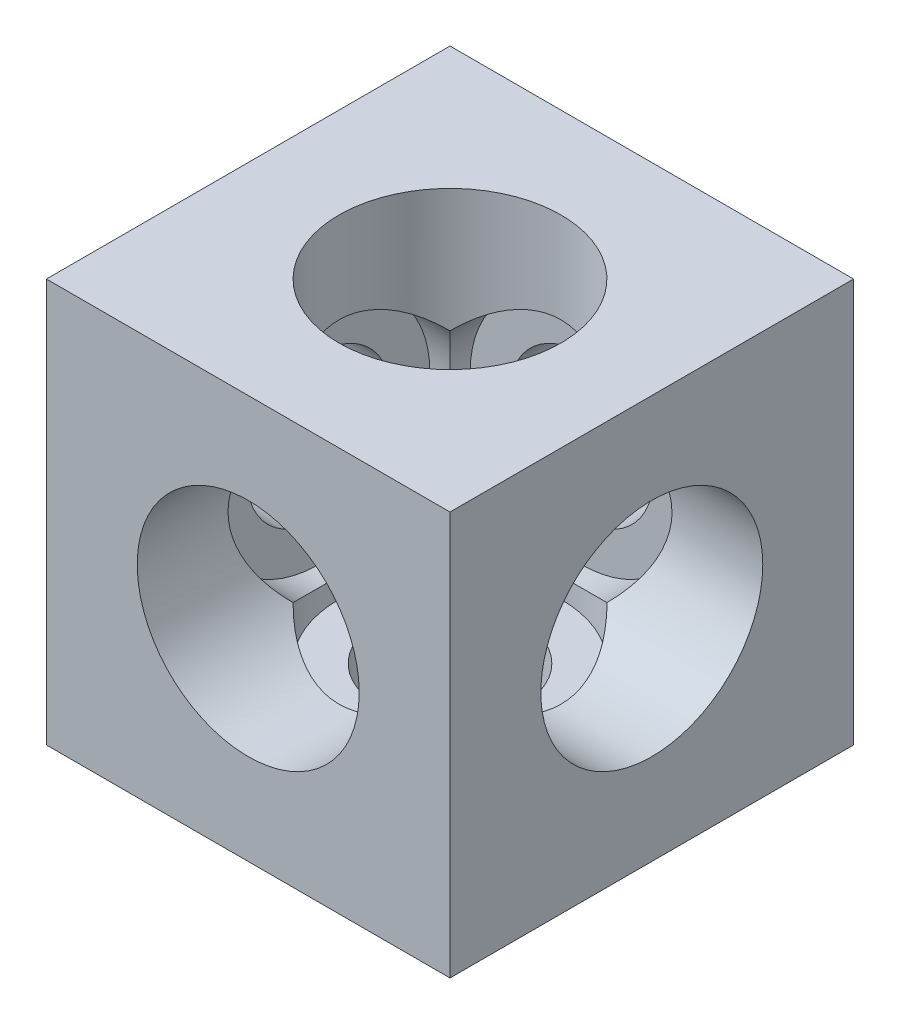
from build123d import *

# Parameters (mm, degrees)
ESQUISSE1_W             = 20
ESQUISSE1_H             = 20
BOSS_EXTRU_1_DEPTH      = 10
ESQUISSE2_R             = 3.57
ENL_V_MAT_EXTRU_1_DEPTH = 21
ESQUISSE3_R             = 5.5
ENL_V_MAT_EXTRU_2_DEPTH = 16.5
ESQUISSE4_R             = 3.57
ENL_V_MAT_EXTRU_3_DEPTH = 21
ESQUISSE5_R             = 5.5
ENL_V_MAT_EXTRU_4_DEPTH = 16.5
ESQUISSE6_R             = 3.57
ENL_V_MAT_EXTRU_5_DEPTH = 21
ESQUISSE7_R             = 5.5
ENL_V_MAT_EXTRU_6_DEPTH = 16.5


with BuildPart() as part:
    # Esquisse1 → Boss.-Extru.1 (new body, symmetric)
    with BuildSketch(Plane.XY):
        Rectangle(ESQUISSE1_W, ESQUISSE1_H)
    extrude(amount=BOSS_EXTRU_1_DEPTH, both=True)

    # Esquisse2 → Enlèv. mat.-Extru.1 (cut, through all)
    with BuildSketch(Plane.XY.offset(10)):
        Circle(ESQUISSE2_R)
    extrude(amount=-ENL_V_MAT_EXTRU_1_DEPTH, mode=Mode.SUBTRACT)

    # Esquisse3 → Enlèv. mat.-Extru.2 (cut)
    with BuildSketch(Plane.XY.offset(10)):
        Circle(ESQUISSE3_R)
    extrude(amount=-ENL_V_MAT_EXTRU_2_DEPTH, mode=Mode.SUBTRACT)

    # Esquisse4 → Enlèv. mat.-Extru.3 (cut, through all)
    with BuildSketch(Plane(origin=(10, 0, 0), x_dir=(0, 0, -1), z_dir=(1, 0, 0))):
        Circle(ESQUISSE4_R)
    extrude(amount=-ENL_V_MAT_EXTRU_3_DEPTH, mode=Mode.SUBTRACT)

    # Esquisse5 → Enlèv. mat.-Extru.4 (cut)
    with BuildSketch(Plane(origin=(10, 0, 0), x_dir=(0, 0, -1), z_dir=(1, 0, 0))):
        Circle(ESQUISSE5_R)
    extrude(amount=-ENL_V_MAT_EXTRU_4_DEPTH, mode=Mode.SUBTRACT)

    # Esquisse6 → Enlèv. mat.-Extru.5 (cut, through all)
    with BuildSketch(Plane(origin=(0, 10, 0), x_dir=(1, 0, 0), z_dir=(0, 1, 0))):
        Circle(ESQUISSE6_R)
    extrude(amount=-ENL_V_MAT_EXTRU_5_DEPTH, mode=Mode.SUBTRACT)

    # Esquisse7 → Enlèv. mat.-Extru.6 (cut)
    with BuildSketch(Plane(origin=(0, 10, 0), x_dir=(1, 0, 0), z_dir=(0, 1, 0))):
        Circle(ESQUISSE7_R)
    extrude(amount=-ENL_V_MAT_EXTRU_6_DEPTH, mode=Mode.SUBTRACT)


solid = part.part
